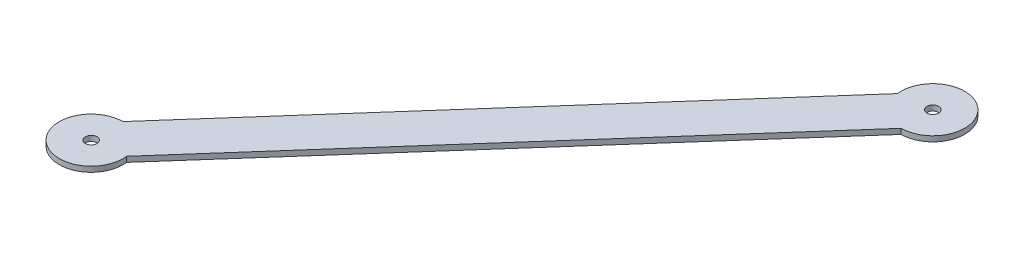
from build123d import *

# Parameters (mm, degrees)
SKETCH1_R           = 3.5
BOSS_EXTRUDE1_DEPTH = 3.175


with BuildPart() as part:
    # Sketch1 → Boss-Extrude1 (new body)
    with BuildSketch(Plane(origin=(0, 0, 0), x_dir=(1, 0, 0), z_dir=(0, 1, 0))):
        with BuildLine():
            Line((98.732784027, 131.104684918), (-117.779499182, -114.300440164))
            ThreePointArc((-117.779499182, -114.300440164), (-130.253183566, -147.635036367), (-98.732784027, -131.104684918))
            Line((-98.732784027, -131.104684918), (117.779499182, 114.300440164))
            ThreePointArc((117.779499182, 114.300440164), (130.253183566, 147.635036367), (98.732784027, 131.104684918))
        make_face()
        with Locations((117.65, 133.35)):
            Circle(SKETCH1_R, mode=Mode.SUBTRACT)
        with Locations((-117.65, -133.35)):
            Circle(SKETCH1_R, mode=Mode.SUBTRACT)
    extrude(amount=BOSS_EXTRUDE1_DEPTH)


solid = part.part
